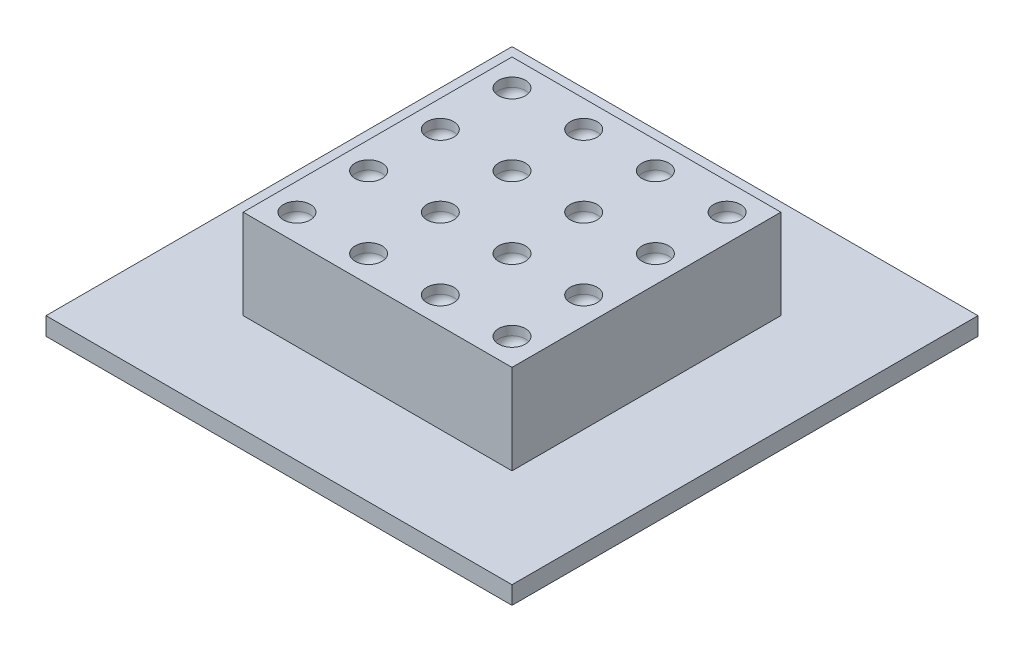
from build123d import *

# Parameters (mm, degrees)
SKETCH1_W              = 15
SKETCH1_H              = 15
BOSS_EXTRUDE1_DEPTH    = 5
SKETCH2_W              = 26
SKETCH2_H              = 26
BOSS_EXTRUDE2_DEPTH    = 1
SKETCH3_R              = 0.75
CUT_EXTRUDE1_DEPTH     = 1
FILLET1_R              = 0.5
LPATTERN1_COUNT        = 4
LPATTERN1_PITCH        = 4
LPATTERN1_COUNT_DIR2   = 4
LPATTERN1_PITCH_DIR2   = 4
FILLET1_OF_LPATTERN1_R = 0.5


with BuildPart() as part:
    # Sketch1 → Boss-Extrude1 (new body)
    with BuildSketch(Plane(origin=(0, 0, 0), x_dir=(1, 0, 0), z_dir=(0, 1, 0))):
        Rectangle(SKETCH1_W, SKETCH1_H)
    extrude(amount=BOSS_EXTRUDE1_DEPTH)

    # Sketch2 → Boss-Extrude2 (add)
    with BuildSketch(Plane.XZ):
        Rectangle(SKETCH2_W, SKETCH2_H)
    extrude(amount=BOSS_EXTRUDE2_DEPTH)

    # Sketch3 → Cut-Extrude1 (cut)
    with BuildSketch(Plane(origin=(0, 5, 0), x_dir=(1, 0, 0), z_dir=(0, 1, 0))):
        with Locations((-6, 6)):
            Circle(SKETCH3_R)
    cut_extrude1 = extrude(amount=-CUT_EXTRUDE1_DEPTH, mode=Mode.SUBTRACT)

    # Fillet1
    fillet1_edges = [part.edges().sort_by_distance(p)[0] for p in [
        (-6.75, 4, -6),
    ]]
    fillet(fillet1_edges, radius=FILLET1_R)

    # LPattern1: Cut-Extrude1 4 × 4
    with Locations(*[(i * LPATTERN1_PITCH, 0, j * LPATTERN1_PITCH_DIR2) for i in range(LPATTERN1_COUNT) for j in range(LPATTERN1_COUNT_DIR2) if (i, j) != (0, 0)]):
        add(cut_extrude1, mode=Mode.SUBTRACT)

    # Fillet1 of LPattern1
    fillet1_of_lpattern1_edges = [part.edges().sort_by_distance(p)[0] for p in [
        (-6.75, 4, -2),
        (-6.75, 4, 2),
        (-6.75, 4, 6),
        (-2.75, 4, -6),
        (-2.75, 4, -2),
        (-2.75, 4, 2),
        (-2.75, 4, 6),
        (1.25, 4, -6),
        (1.25, 4, -2),
        (1.25, 4, 2),
        (1.25, 4, 6),
        (5.25, 4, -6),
        (5.25, 4, -2),
        (5.25, 4, 2),
        (5.25, 4, 6),
    ]]
    fillet(fillet1_of_lpattern1_edges, radius=FILLET1_OF_LPATTERN1_R)


solid = part.part
